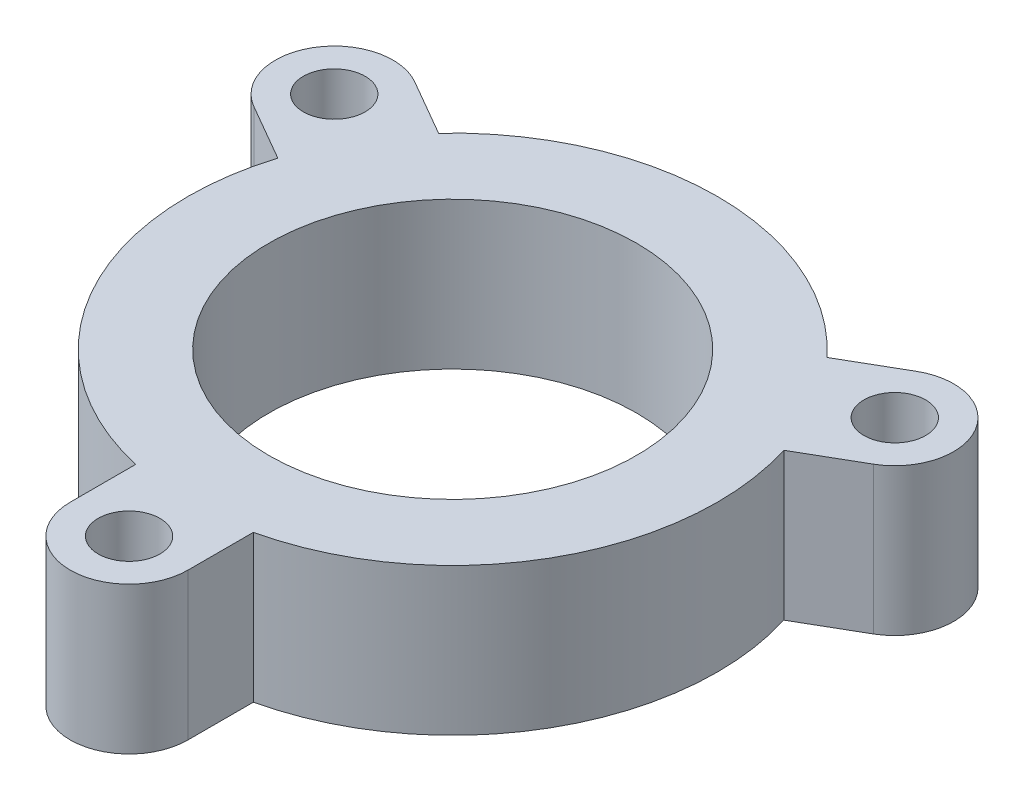
from build123d import *

# Parameters (mm, degrees)
SKETCH1_R           = 2.1
SKETCH1_R_2         = 12.5
BOSS_EXTRUDE1_DEPTH = 10


with BuildPart() as part:
    # Sketch1 → Boss-Extrude1 (new body)
    with BuildSketch(Plane(origin=(0, 0, 0), x_dir=(1, 0, 0), z_dir=(0, 1, 0))):
        with BuildLine():
            ThreePointArc((-4, -22), (0, -26), (4, -22))
            Line((4, -22), (4, -17.549928775))
            ThreePointArc((4, -17.549928775), (15.588457268, -9), (17.198684154, 5.310862772))
            Line((17.198684154, 5.310862772), (21.052558883, 7.535898385))
            ThreePointArc((21.052558883, 7.535898385), (22.516660498, 13), (17.052558883, 14.464101615))
            Line((17.052558883, 14.464101615), (13.198684154, 12.239066003))
            ThreePointArc((13.198684154, 12.239066003), (0, 18), (-13.198684154, 12.239066003))
            Line((-13.198684154, 12.239066003), (-17.052558883, 14.464101615))
            ThreePointArc((-17.052558883, 14.464101615), (-22.516660498, 13), (-21.052558883, 7.535898385))
            Line((-21.052558883, 7.535898385), (-17.198684154, 5.310862772))
            ThreePointArc((-17.198684154, 5.310862772), (-15.588457268, -9), (-4, -17.549928775))
            Line((-4, -17.549928775), (-4, -22))
        make_face()
        with Locations((0, -22)):
            Circle(SKETCH1_R, mode=Mode.SUBTRACT)
        Circle(SKETCH1_R_2, mode=Mode.SUBTRACT)
        with Locations((19.052558883, 11)):
            Circle(SKETCH1_R, mode=Mode.SUBTRACT)
        with Locations((-19.052558883, 11)):
            Circle(SKETCH1_R, mode=Mode.SUBTRACT)
    extrude(amount=BOSS_EXTRUDE1_DEPTH)


solid = part.part
